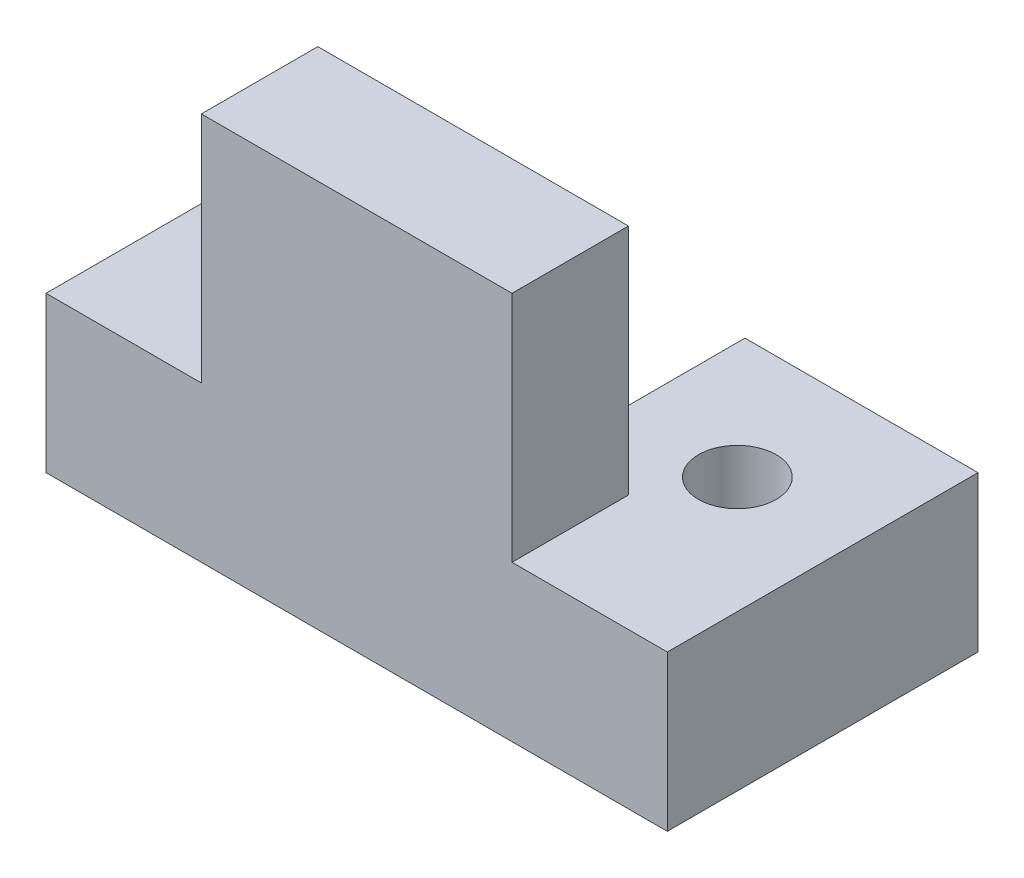
from build123d import *

# Parameters (mm, degrees)
SKETCH1_W           = 101.6
SKETCH1_H           = 50.8
BOSS_EXTRUDE1_DEPTH = 25.4
SKETCH2_W           = 25.4
SKETCH2_H           = 19.05
CUT_EXTRUDE1_DEPTH  = 26.4
SKETCH5_W           = 50.8
SKETCH5_H           = 19.05
BOSS_EXTRUDE3_DEPTH = 38.1
SKETCH7_R           = 6.35
CUT_EXTRUDE2_DEPTH  = 26.4


with BuildPart() as part:
    # Sketch1 → Boss-Extrude1 (new body)
    with BuildSketch(Plane(origin=(0, 0, 0), x_dir=(1, 0, 0), z_dir=(0, 1, 0))):
        with Locations((-7.687438987, 79.657257194)):
            Rectangle(SKETCH1_W, SKETCH1_H)
    extrude(amount=BOSS_EXTRUDE1_DEPTH)

    # Sketch2 → Cut-Extrude1 (cut, through all)
    with BuildSketch(Plane(origin=(0, 25.4, 0), x_dir=(1, 0, 0), z_dir=(0, 1, 0))):
        with Locations((-7.687438987, 95.532257194)):
            Rectangle(SKETCH2_W, SKETCH2_H)
    extrude(amount=-CUT_EXTRUDE1_DEPTH, mode=Mode.SUBTRACT)

    # Sketch5 → Boss-Extrude3 (add)
    with BuildSketch(Plane(origin=(0, 25.4, 0), x_dir=(1, 0, 0), z_dir=(0, 1, 0))):
        with Locations((-7.687438987, 63.782257194)):
            Rectangle(SKETCH5_W, SKETCH5_H)
    extrude(amount=BOSS_EXTRUDE3_DEPTH)

    # Sketch7 → Cut-Extrude2 (cut, through all)
    with BuildSketch(Plane(origin=(0, 25.4, 0), x_dir=(1, 0, 0), z_dir=(0, 1, 0))):
        with Locations((24.062561013, 84.755702101)):
            Circle(SKETCH7_R)
    extrude(amount=-CUT_EXTRUDE2_DEPTH, mode=Mode.SUBTRACT)


solid = part.part
